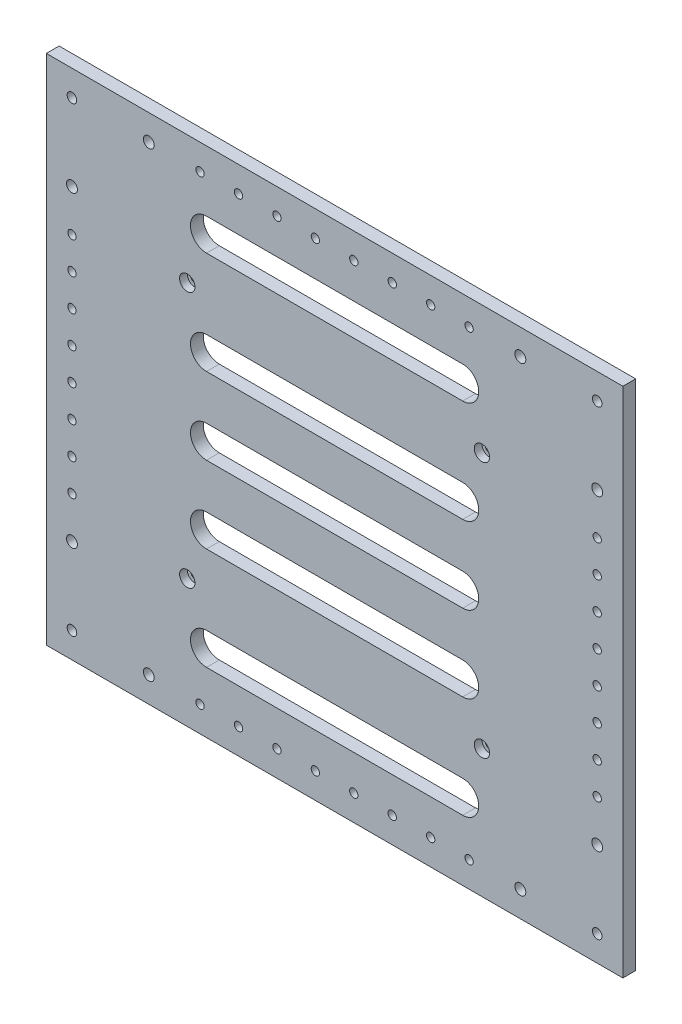
from build123d import *

# Parameters (mm, degrees)
SKETCH_1_W          = 450
SKETCH_1_H          = 400
SKETCH_1_R          = 3.25
EXTRUDE_1_DEPTH     = 10
SKETCH_2_R          = 6
CUT_EXTRUDE_1_DEPTH = 6
SKETCH_3_R          = 3.75
SKETCH_3_R_2        = 4.25
CUT_EXTRUDE_2_DEPTH = 50
CUT_EXTRUDE_3_DEPTH = 50
SKETCH_5_R          = 3.25
CUT_EXTRUDE_4_DEPTH = 90


with BuildPart() as part:
    # 草图1 → 凸台-拉伸1 (new body)
    with BuildSketch(Plane.XY):
        Rectangle(SKETCH_1_W, SKETCH_1_H)
        with Locations((-115, 100)):
            Circle(SKETCH_1_R, mode=Mode.SUBTRACT)
        with Locations((115, 100)):
            Circle(SKETCH_1_R, mode=Mode.SUBTRACT)
        with Locations((115, -100)):
            Circle(SKETCH_1_R, mode=Mode.SUBTRACT)
        with Locations((-115, -100)):
            Circle(SKETCH_1_R, mode=Mode.SUBTRACT)
    extrude(amount=EXTRUDE_1_DEPTH)

    # 草图2 → 切除-拉伸1 (cut)
    with BuildSketch(Plane.XY.offset(10)):
        with Locations((-115, 100)):
            Circle(SKETCH_2_R)
        with Locations((115, 100)):
            Circle(SKETCH_2_R)
        with Locations((115, -100)):
            Circle(SKETCH_2_R)
        with Locations((-115, -100)):
            Circle(SKETCH_2_R)
    extrude(amount=-CUT_EXTRUDE_1_DEPTH, mode=Mode.SUBTRACT)

    # 草图3 → 切除-拉伸2 (cut)
    with BuildSketch(Plane.XY.offset(10)):
        with Locations((205, -180)):
            Circle(SKETCH_3_R)
        with Locations((205, -120)):
            Circle(SKETCH_3_R_2)
        with Locations((145, -180)):
            Circle(SKETCH_3_R_2)
        with Locations((145, 180)):
            Circle(SKETCH_3_R_2)
        with Locations((205, 120)):
            Circle(SKETCH_3_R_2)
        with Locations((205, 180)):
            Circle(SKETCH_3_R)
        with Locations((-205, 180)):
            Circle(SKETCH_3_R)
        with Locations((-205, 120)):
            Circle(SKETCH_3_R_2)
        with Locations((-145, 180)):
            Circle(SKETCH_3_R_2)
        with Locations((-145, -180)):
            Circle(SKETCH_3_R_2)
        with Locations((-205, -120)):
            Circle(SKETCH_3_R_2)
        with Locations((-205, -180)):
            Circle(SKETCH_3_R)
    extrude(amount=-CUT_EXTRUDE_2_DEPTH, mode=Mode.SUBTRACT)

    # 草图4 → 切除-拉伸3 (cut)
    with BuildSketch(Plane.XY.offset(10)):
        with BuildLine():
            Line((100, -12.5), (-100, -12.5))
            ThreePointArc((-100, -12.5), (-112.5, 0), (-100, 12.5))
            Line((-100, 12.5), (100, 12.5))
            ThreePointArc((100, 12.5), (112.5, 0), (100, -12.5))
        make_face()
        with BuildLine():
            Line((100, 47.5), (-100, 47.5))
            ThreePointArc((-100, 47.5), (-112.5, 60), (-100, 72.5))
            Line((-100, 72.5), (100, 72.5))
            ThreePointArc((100, 72.5), (112.5, 60), (100, 47.5))
        make_face()
        with BuildLine():
            Line((100, -47.5), (-100, -47.5))
            ThreePointArc((-100, -47.5), (-112.5, -60), (-100, -72.5))
            Line((-100, -72.5), (100, -72.5))
            ThreePointArc((100, -72.5), (112.5, -60), (100, -47.5))
        make_face()
        with BuildLine():
            Line((100, 127.5), (-100, 127.5))
            ThreePointArc((-100, 127.5), (-112.5, 140), (-100, 152.5))
            Line((-100, 152.5), (100, 152.5))
            ThreePointArc((100, 152.5), (112.5, 140), (100, 127.5))
        make_face()
        with BuildLine():
            Line((100, -127.5), (-100, -127.5))
            ThreePointArc((-100, -127.5), (-112.5, -140), (-100, -152.5))
            Line((-100, -152.5), (100, -152.5))
            ThreePointArc((100, -152.5), (112.5, -140), (100, -127.5))
        make_face()
    extrude(amount=-CUT_EXTRUDE_3_DEPTH, mode=Mode.SUBTRACT)

    # 草图5 → 切除-拉伸4 (cut)
    with BuildSketch(Plane.XY.offset(10)):
        with Locations((-15, 180)):
            Circle(SKETCH_5_R)
        with Locations((-45, 180)):
            Circle(SKETCH_5_R)
        with Locations((-75, 180)):
            Circle(SKETCH_5_R)
        with Locations((-105, 180)):
            Circle(SKETCH_5_R)
        with Locations((15, 180)):
            Circle(SKETCH_5_R)
        with Locations((45, 180)):
            Circle(SKETCH_5_R)
        with Locations((75, 180)):
            Circle(SKETCH_5_R)
        with Locations((105, 180)):
            Circle(SKETCH_5_R)
        with Locations((105, -180)):
            Circle(SKETCH_5_R)
        with Locations((75, -180)):
            Circle(SKETCH_5_R)
        with Locations((45, -180)):
            Circle(SKETCH_5_R)
        with Locations((15, -180)):
            Circle(SKETCH_5_R)
        with Locations((-105, -180)):
            Circle(SKETCH_5_R)
        with Locations((-75, -180)):
            Circle(SKETCH_5_R)
        with Locations((-45, -180)):
            Circle(SKETCH_5_R)
        with Locations((-15, -180)):
            Circle(SKETCH_5_R)
        with Locations((205, 12.5)):
            Circle(SKETCH_5_R)
        with Locations((205, 37.5)):
            Circle(SKETCH_5_R)
        with Locations((205, 62.5)):
            Circle(SKETCH_5_R)
        with Locations((205, 87.5)):
            Circle(SKETCH_5_R)
        with Locations((205, -87.5)):
            Circle(SKETCH_5_R)
        with Locations((205, -62.5)):
            Circle(SKETCH_5_R)
        with Locations((205, -37.5)):
            Circle(SKETCH_5_R)
        with Locations((205, -12.5)):
            Circle(SKETCH_5_R)
        with Locations((-205, -12.5)):
            Circle(SKETCH_5_R)
        with Locations((-205, -37.5)):
            Circle(SKETCH_5_R)
        with Locations((-205, -62.5)):
            Circle(SKETCH_5_R)
        with Locations((-205, -87.5)):
            Circle(SKETCH_5_R)
        with Locations((-205, 87.5)):
            Circle(SKETCH_5_R)
        with Locations((-205, 62.5)):
            Circle(SKETCH_5_R)
        with Locations((-205, 37.5)):
            Circle(SKETCH_5_R)
        with Locations((-205, 12.5)):
            Circle(SKETCH_5_R)
    extrude(amount=-CUT_EXTRUDE_4_DEPTH, mode=Mode.SUBTRACT)


solid = part.part
